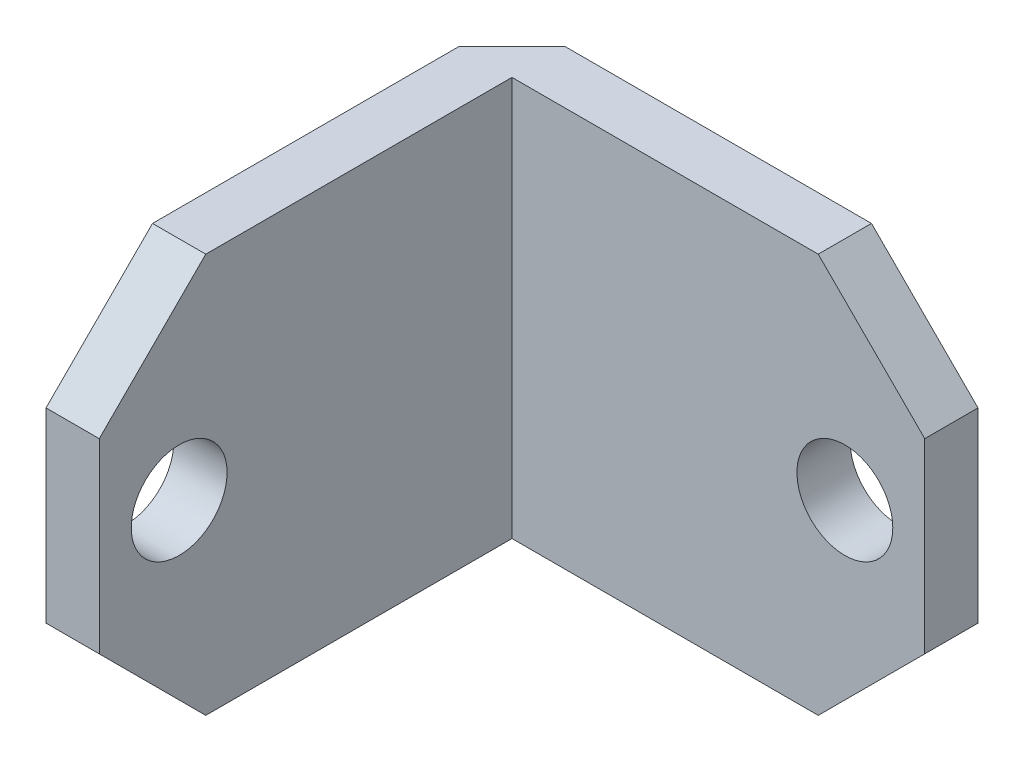
from build123d import *

# Parameters (mm, degrees)
BOSS_EXTRUDE1_DEPTH = 19.05
SKETCH2_R           = 2.286
CUT_EXTRUDE1_DEPTH  = 2.54
SKETCH3_R           = 2.286
CUT_EXTRUDE2_DEPTH  = 2.54
CHAMFER1_SIZE       = 5.08
CHAMFER2_SIZE       = 2.54


with BuildPart() as part:
    # Sketch1 → Boss-Extrude1 (new body)
    with BuildSketch(Plane(origin=(0, 0, 0), x_dir=(1, 0, 0), z_dir=(0, 1, 0))):
        Polygon((22.225, 22.225), (22.225, 19.685), (2.54, 19.685), (2.54, 0), (0, 0), (0, 22.225), align=None)
    extrude(amount=BOSS_EXTRUDE1_DEPTH)

    # Sketch2 → Cut-Extrude1 (cut)
    with BuildSketch(Plane.XY.offset(-19.685)):
        with Locations((18.415, 9.525)):
            Circle(SKETCH2_R)
    extrude(amount=-CUT_EXTRUDE1_DEPTH, mode=Mode.SUBTRACT)

    # Sketch3 → Cut-Extrude2 (cut)
    with BuildSketch(Plane(origin=(2.54, 0, 0), x_dir=(0, 0, -1), z_dir=(1, 0, 0))):
        with Locations((3.81, 9.525)):
            Circle(SKETCH3_R)
    extrude(amount=-CUT_EXTRUDE2_DEPTH, mode=Mode.SUBTRACT)

    # Chamfer1
    chamfer1_edges = [part.edges().sort_by_distance(p)[0] for p in [
        (22.225, 0, -20.955),
        (1.27, 19.05, 0),
        (22.225, 19.05, -20.955),
        (1.27, 0, 0),
    ]]
    chamfer(chamfer1_edges, length=CHAMFER1_SIZE)

    # Chamfer2
    chamfer2_edges = [part.edges().sort_by_distance(p)[0] for p in [
        (0, 9.525, -22.225),
    ]]
    chamfer(chamfer2_edges, length=CHAMFER2_SIZE)


solid = part.part
